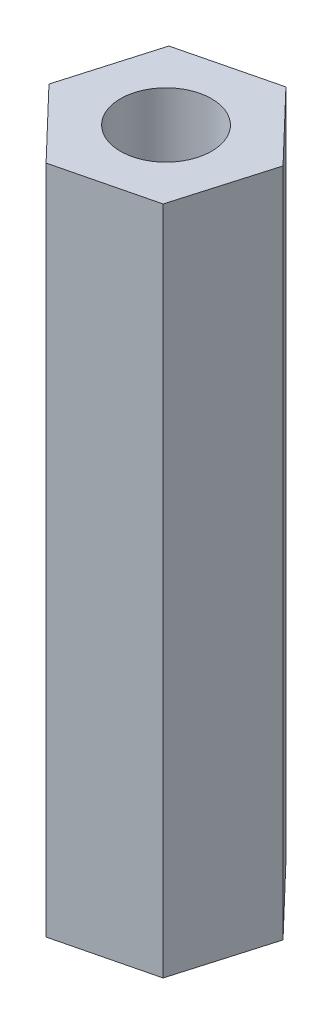
from build123d import *

# Parameters (mm, degrees)
BOSS_EXTRUDE1_DEPTH = 25.4
SKETCH3_R           = 1.7272
CUT_EXTRUDE2_DEPTH  = 26.4


with BuildPart() as part:
    # Sketch1 → Boss-Extrude1 (new body)
    with BuildSketch(Plane(origin=(0, 0, 0), x_dir=(1, 0, 0), z_dir=(0, 1, 0))):
        Polygon((-2.767735883, 3.334911674), (-1.744793251, 6.855482892), (-4.282226046, 9.501662807), (-7.842601473, 8.627271504), (-8.865544105, 5.106700285), (-6.32811131, 2.46052037), align=None)
    extrude(amount=BOSS_EXTRUDE1_DEPTH)

    # Sketch3 → Cut-Extrude2 (cut, through all)
    with BuildSketch(Plane.XZ):
        with Locations((-5.305168678, -5.981091589)):
            Circle(SKETCH3_R)
    extrude(amount=-CUT_EXTRUDE2_DEPTH, mode=Mode.SUBTRACT)


solid = part.part
